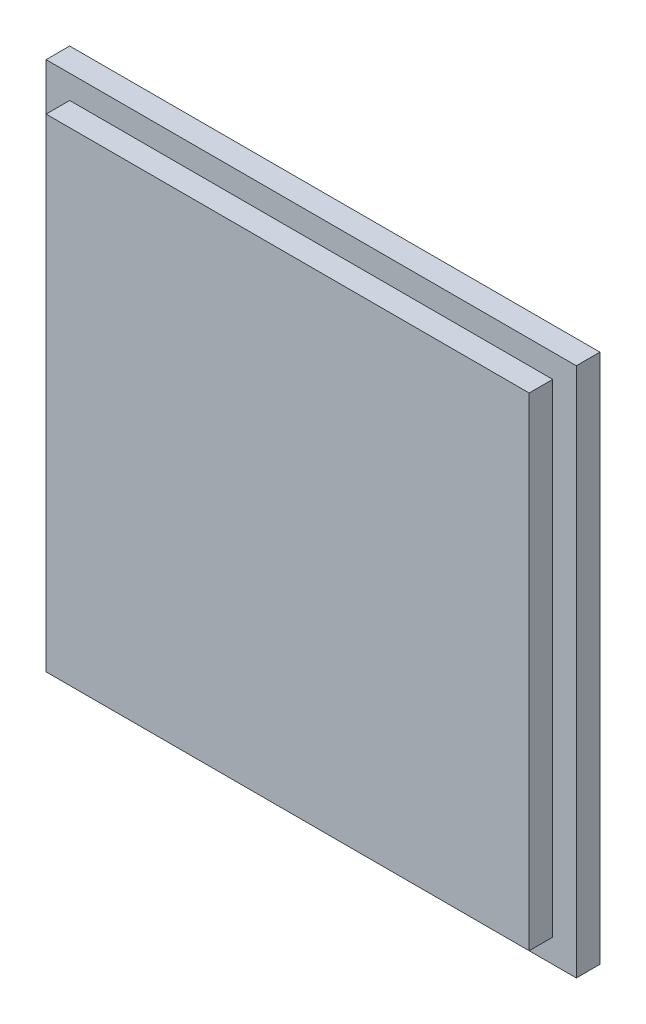
from build123d import *

# Parameters (mm, degrees)
SKETCH2_W           = 56.2
SKETCH2_H           = 56.2
BOSS_EXTRUDE1_DEPTH = 2.5
SKETCH3_W           = 51.2
SKETCH3_H           = 51.2
BOSS_EXTRUDE2_DEPTH = 2.5
CUT_EXTRUDE1_DEPTH  = 1
BOSS_EXTRUDE3_DEPTH = 1


with BuildPart() as part:
    # Sketch2 → Boss-Extrude1 (new body)
    with BuildSketch(Plane.XY):
        Rectangle(SKETCH2_W, SKETCH2_H)
    extrude(amount=BOSS_EXTRUDE1_DEPTH)

    # Sketch3 → Boss-Extrude2 (add)
    with BuildSketch(Plane.XY.offset(2.5)):
        Rectangle(SKETCH3_W, SKETCH3_H)
    extrude(amount=BOSS_EXTRUDE2_DEPTH)

    # Sketch4 → Cut-Extrude1 (cut)
    with BuildSketch(Plane(origin=(0, 0, 0), x_dir=(-1, 0, 0), z_dir=(0, 0, -1))):
        Polygon((0, 20), (-17.320508076, -10), (17.320508076, -10), align=None)
    extrude(amount=-CUT_EXTRUDE1_DEPTH, mode=Mode.SUBTRACT)

    # Sketch5 → Boss-Extrude3 (add)
    with BuildSketch(Plane(origin=(0, 0, 1), x_dir=(-1, 0, 0), z_dir=(0, 0, -1))):
        Polygon((-1.517755642, 12.461495331), (-5.561610901, 1.642869574), (-0.574357926, 2.168045581), (-2.883213262, -4.921830522), (-4.196153281, -3.661408103), (-3.303354068, -8.387992172), (0.320360384, -5.447006529), (-1.517755642, -5.447006529), (2.631134818, 5.109031224), (-1.465238042, 4.951478422), (2.368546814, 12.356460129), align=None)
    extrude(amount=BOSS_EXTRUDE3_DEPTH)


solid = part.part
